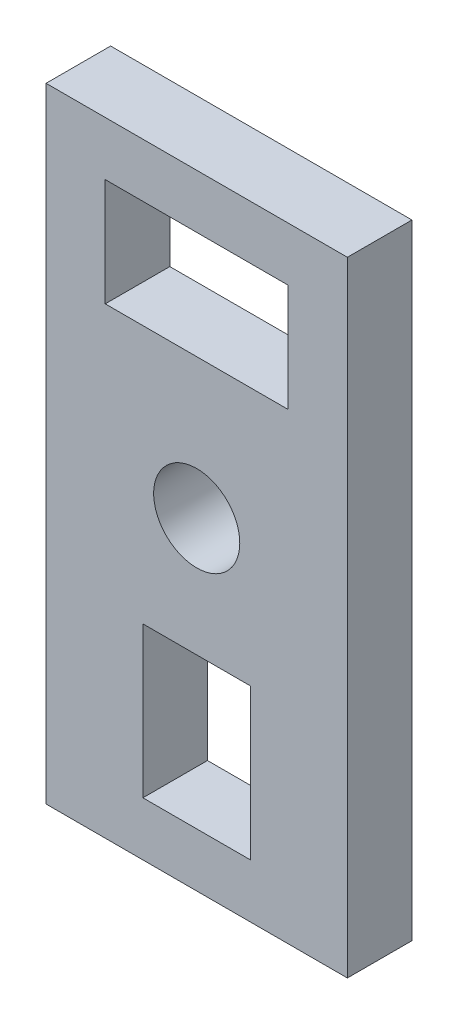
from build123d import *

# Parameters (mm, degrees)
ESQUISSE1_W             = 20
ESQUISSE1_H             = 40
BOSS_EXTRU_1_DEPTH      = 3
ENL_V_MAT_EXTRU_1_REACH = 5
ESQUISSE2_R             = 2
ESQUISSE2_W             = 8.5
ESQUISSE2_H             = 5
ESQUISSE2_W_2           = 5
ESQUISSE2_H_2           = 7
ENL_V_MAT_EXTRU_2_REACH = 5
ESQUISSE3_W             = 14
ESQUISSE3_H             = 5
ESQUISSE3_H_2           = 6


with BuildPart() as part:
    # Esquisse1 → Boss.-Extru.1 (new body)
    with BuildSketch(Plane.XY):
        with Locations((10, 20)):
            Rectangle(ESQUISSE1_W, ESQUISSE1_H)
    extrude(amount=BOSS_EXTRU_1_DEPTH)

    # Esquisse2 → Enlèv. mat.-Extru.1 (cut, up to next)
    with BuildSketch(Plane.XY.offset(3), mode=Mode.PRIVATE) as enl_v_mat_extru_1_sk1:
        with Locations((10, 20)):
            Circle(ESQUISSE2_R)
    enl_v_mat_extru_1_tool1 = extrude(enl_v_mat_extru_1_sk1.sketch, amount=-ENL_V_MAT_EXTRU_1_REACH, mode=Mode.PRIVATE) & part.part
    add(enl_v_mat_extru_1_tool1.solids().sort_by_distance((10, 20, 3))[0], mode=Mode.SUBTRACT)
    # Esquisse2 → Enlèv. mat.-Extru.1 (cut, up to next)
    with BuildSketch(Plane.XY.offset(3), mode=Mode.PRIVATE) as enl_v_mat_extru_1_sk2:
        with Locations((10, 29)):
            Rectangle(ESQUISSE2_W, ESQUISSE2_H)
    enl_v_mat_extru_1_tool2 = extrude(enl_v_mat_extru_1_sk2.sketch, amount=-ENL_V_MAT_EXTRU_1_REACH, mode=Mode.PRIVATE) & part.part
    add(enl_v_mat_extru_1_tool2.solids().sort_by_distance((10, 29, 3))[0], mode=Mode.SUBTRACT)
    # Esquisse2 → Enlèv. mat.-Extru.1 (cut, up to next)
    with BuildSketch(Plane.XY.offset(3), mode=Mode.PRIVATE) as enl_v_mat_extru_1_sk3:
        with Locations((10, 11)):
            Rectangle(ESQUISSE2_W_2, ESQUISSE2_H_2)
    enl_v_mat_extru_1_tool3 = extrude(enl_v_mat_extru_1_sk3.sketch, amount=-ENL_V_MAT_EXTRU_1_REACH, mode=Mode.PRIVATE) & part.part
    add(enl_v_mat_extru_1_tool3.solids().sort_by_distance((10, 11, 3))[0], mode=Mode.SUBTRACT)

    # Esquisse3 → Enlèv. mat.-Extru.2 (cut, up to next)
    with BuildSketch(Plane.XY.offset(3), mode=Mode.PRIVATE) as enl_v_mat_extru_2_sk1:
        Polygon((0, 40), (0, 0), (3, 0), (3, 5), (3, 34), (3, 40), align=None)
    enl_v_mat_extru_2_tool1 = extrude(enl_v_mat_extru_2_sk1.sketch, amount=-ENL_V_MAT_EXTRU_2_REACH, mode=Mode.PRIVATE) & part.part
    add(enl_v_mat_extru_2_tool1.solids().sort_by_distance((1.5, 20, 3))[0], mode=Mode.SUBTRACT)
    # Esquisse3 → Enlèv. mat.-Extru.2 (cut, up to next)
    with BuildSketch(Plane.XY.offset(3), mode=Mode.PRIVATE) as enl_v_mat_extru_2_sk2:
        Polygon((17, 5), (17, 0), (20, 0), (20, 40), (17, 40), (17, 34), align=None)
    enl_v_mat_extru_2_tool2 = extrude(enl_v_mat_extru_2_sk2.sketch, amount=-ENL_V_MAT_EXTRU_2_REACH, mode=Mode.PRIVATE) & part.part
    add(enl_v_mat_extru_2_tool2.solids().sort_by_distance((18.5, 20, 3))[0], mode=Mode.SUBTRACT)
    # Esquisse3 → Enlèv. mat.-Extru.2 (cut, up to next)
    with BuildSketch(Plane.XY.offset(3), mode=Mode.PRIVATE) as enl_v_mat_extru_2_sk3:
        with Locations((10, 2.5)):
            Rectangle(ESQUISSE3_W, ESQUISSE3_H)
    enl_v_mat_extru_2_tool3 = extrude(enl_v_mat_extru_2_sk3.sketch, amount=-ENL_V_MAT_EXTRU_2_REACH, mode=Mode.PRIVATE) & part.part
    add(enl_v_mat_extru_2_tool3.solids().sort_by_distance((10, 2.5, 3))[0], mode=Mode.SUBTRACT)
    # Esquisse3 → Enlèv. mat.-Extru.2 (cut, up to next)
    with BuildSketch(Plane.XY.offset(3), mode=Mode.PRIVATE) as enl_v_mat_extru_2_sk4:
        with Locations((10, 37)):
            Rectangle(ESQUISSE3_W, ESQUISSE3_H_2)
    enl_v_mat_extru_2_tool4 = extrude(enl_v_mat_extru_2_sk4.sketch, amount=-ENL_V_MAT_EXTRU_2_REACH, mode=Mode.PRIVATE) & part.part
    add(enl_v_mat_extru_2_tool4.solids().sort_by_distance((10, 37, 3))[0], mode=Mode.SUBTRACT)


solid = part.part
